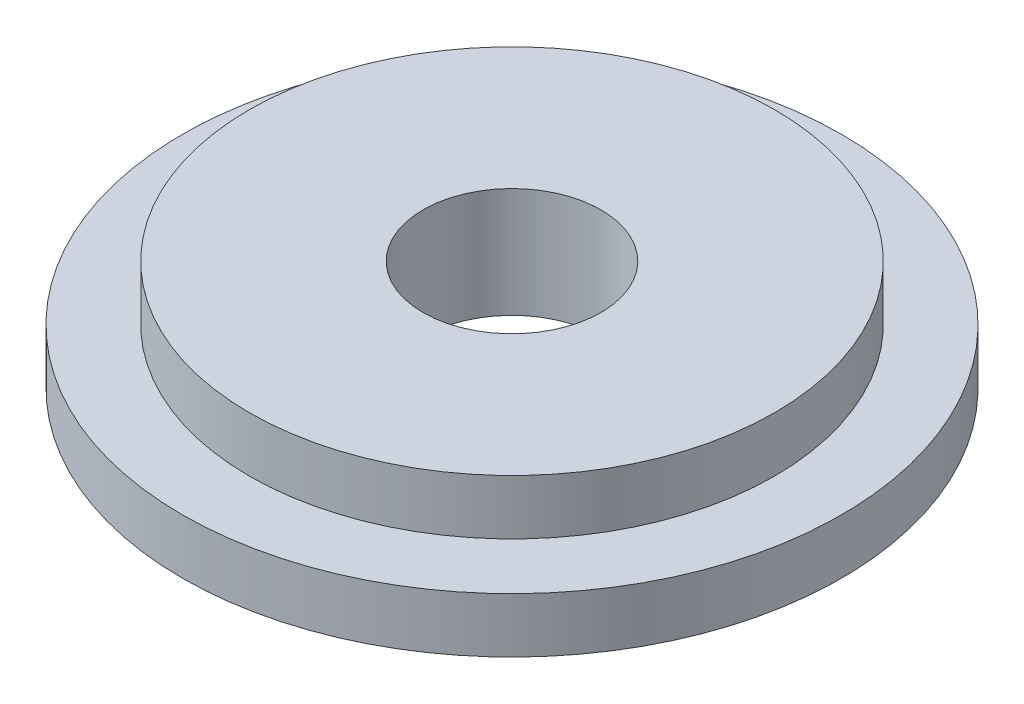
from build123d import *

# Parameters (mm, degrees)
CROQUIS1_R              = 23.9
CROQUIS1_R_2            = 8.1
SALIENTE_EXTRUIR1_DEPTH = 5
SALIENTE_EXTRUIR2_START = -5
CROQUIS1_3_R            = 30
CROQUIS1_3_R_2          = 8.1
SALIENTE_EXTRUIR2_DEPTH = 5


with BuildPart() as part:
    # Croquis1 → Saliente-Extruir1 (new body)
    with BuildSketch(Plane(origin=(0, 0, 0), x_dir=(1, 0, 0), z_dir=(0, 1, 0))):
        Circle(CROQUIS1_R)
        Circle(CROQUIS1_R_2, mode=Mode.SUBTRACT)
    extrude(amount=SALIENTE_EXTRUIR1_DEPTH)

    # Croquis1_3 → Saliente-Extruir2 (add)
    with BuildSketch(Plane(origin=(0, 0, 0), x_dir=(1, 0, 0), z_dir=(0, 1, 0)).offset(SALIENTE_EXTRUIR2_START)):
        Circle(CROQUIS1_3_R)
        Circle(CROQUIS1_3_R_2, mode=Mode.SUBTRACT)
    extrude(amount=SALIENTE_EXTRUIR2_DEPTH)


solid = part.part
